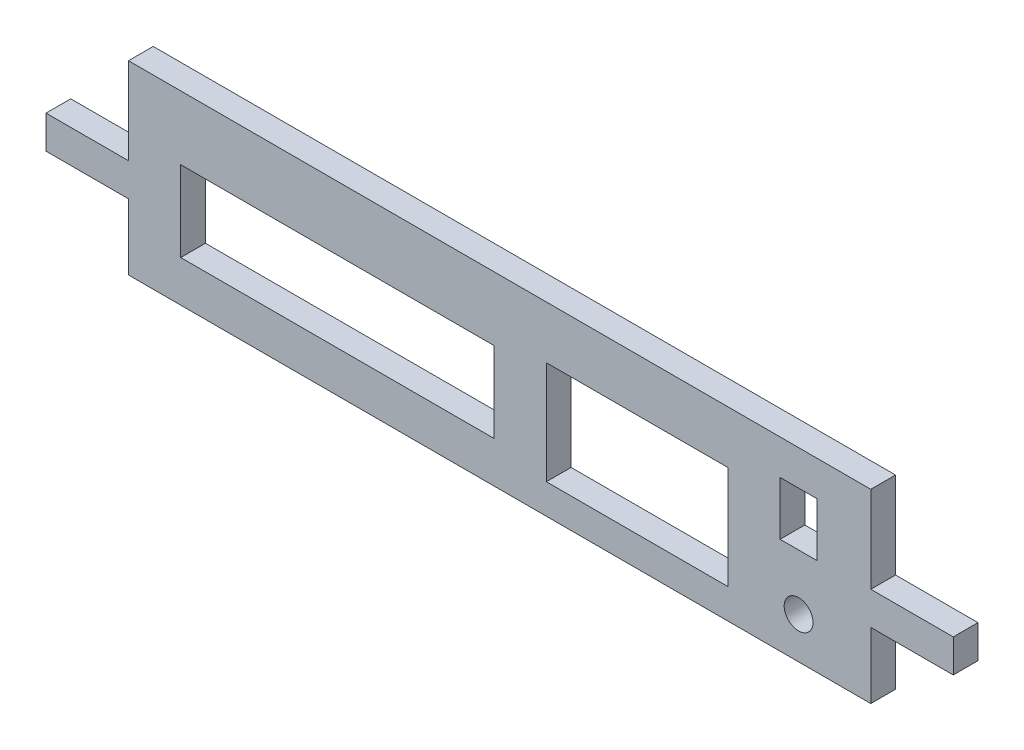
from build123d import *

# Parameters (mm, degrees)
ESBO_O1_R                = 3.5
ESBO_O1_W                = 76
ESBO_O1_H                = 19.5
ESBO_O1_W_2              = 44
ESBO_O1_H_2              = 25
ESBO_O1_W_3              = 9
ESBO_O1_H_3              = 13
RESSALTO_EXTRUS_O1_DEPTH = 6


with BuildPart() as part:
    # Esboço1 → Ressalto-extrusão1 (new body)
    with BuildSketch(Plane.XY):
        Polygon((-90, -6.5), (-90, -22.5), (90, -22.5), (90, -6.5), (110, -6.5), (110, 1.5), (90, 1.5), (90, 22.5), (-90, 22.5), (-90, 1.5), (-110, 1.5), (-110, -6.5), align=None)
        with Locations((72.5, -12.5)):
            Circle(ESBO_O1_R, mode=Mode.SUBTRACT)
        with Locations((-39.333333333, -2.75)):
            Rectangle(ESBO_O1_W, ESBO_O1_H, mode=Mode.SUBTRACT)
        with Locations((33.333333333, -2.75)):
            Rectangle(ESBO_O1_W_2, ESBO_O1_H_2, mode=Mode.SUBTRACT)
        with Locations((72.5, 7.5)):
            Rectangle(ESBO_O1_W_3, ESBO_O1_H_3, mode=Mode.SUBTRACT)
    extrude(amount=RESSALTO_EXTRUS_O1_DEPTH)


solid = part.part
